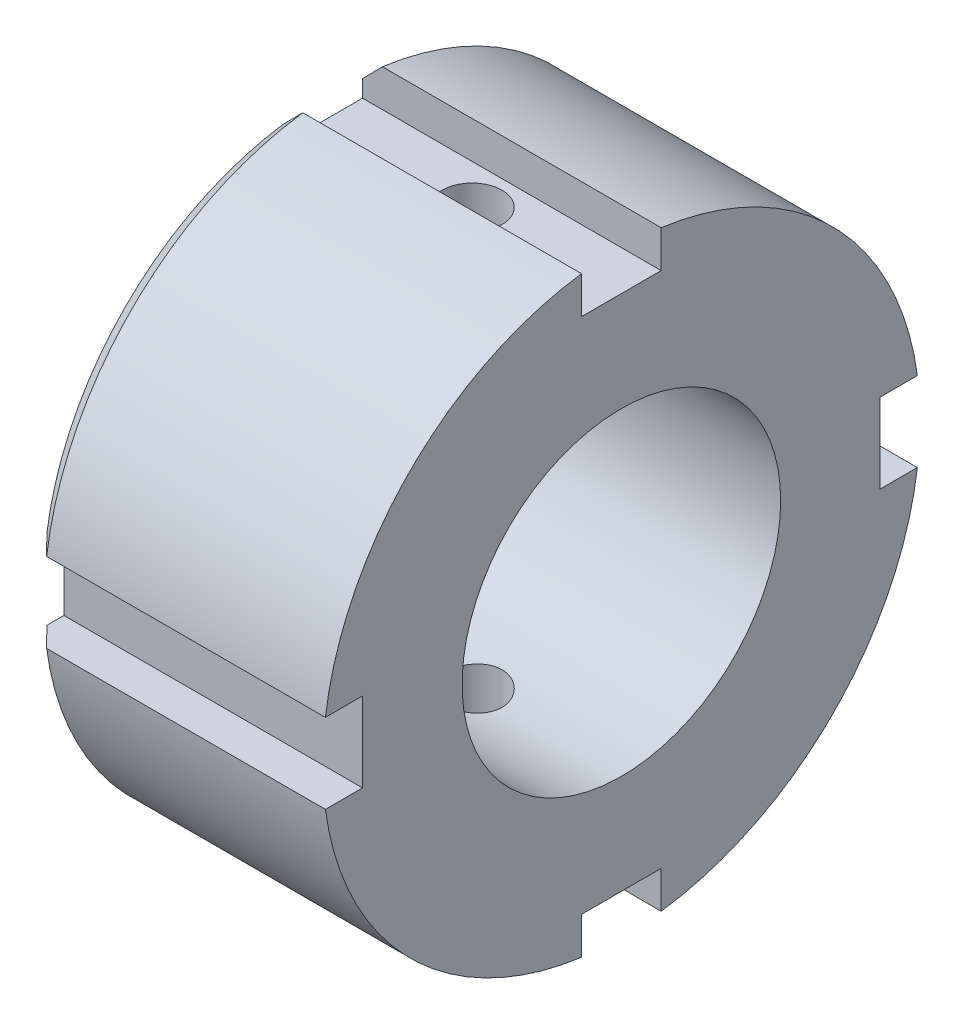
from build123d import *

# Parameters (mm, degrees)
SKETCH1_R               = 15
BOSS_EXTRUDE1_DEPTH     = 15
SKETCH2_R               = 8
CUT_EXTRUDE1_DEPTH      = 16
CHAMFER1_SIZE           = 1
SKETCH3_W               = 4
SKETCH3_H               = 4
CUT_EXTRUDE2_DEPTH      = 16
CIRPATTERN1_COUNT       = 4
SKETCH4_R               = 1.5
CUT_EXTRUDE4_DEPTH      = 18
CUT_EXTRUDE4_DEPTH_BACK = 15.866068747


with BuildPart() as part:
    # Sketch1 → Boss-Extrude1 (new body)
    with BuildSketch(Plane(origin=(0, 0, 0), x_dir=(0, 0, -1), z_dir=(1, 0, 0))):
        Circle(SKETCH1_R)
    extrude(amount=BOSS_EXTRUDE1_DEPTH)

    # Sketch2 → Cut-Extrude1 (cut, through all)
    with BuildSketch(Plane(origin=(15, 0, 0), x_dir=(0, 0, -1), z_dir=(1, 0, 0))):
        Circle(SKETCH2_R)
    extrude(amount=-CUT_EXTRUDE1_DEPTH, mode=Mode.SUBTRACT)

    # Chamfer1
    chamfer1_edges = [part.edges().sort_by_distance(p)[0] for p in [
        (0, 0, 15),
    ]]
    chamfer(chamfer1_edges, length=CHAMFER1_SIZE)

    # Sketch3 → Cut-Extrude2 (cut, through all)
    with BuildSketch(Plane(origin=(15, 0, 0), x_dir=(0, 0, -1), z_dir=(1, 0, 0))):
        with Locations((0, 15)):
            Rectangle(SKETCH3_W, SKETCH3_H)
    cut_extrude2 = extrude(amount=-CUT_EXTRUDE2_DEPTH, mode=Mode.SUBTRACT)

    # CirPattern1: Cut-Extrude2 ×4 about axis
    cirpattern1_axis = Axis((0, 0, 0), (1, 0, 0))
    for i in range(1, CIRPATTERN1_COUNT):
        add(cut_extrude2.rotate(cirpattern1_axis, i * 360 / CIRPATTERN1_COUNT), mode=Mode.SUBTRACT)

    # Sketch4 → Cut-Extrude4 (cut, two sides)
    with BuildSketch(Plane(origin=(0, 0, 0), x_dir=(1, 0, 0), z_dir=(0, 1, 0))) as cut_extrude4_sk:
        with Locations((7.5, 0)):
            Circle(SKETCH4_R)
    extrude(amount=CUT_EXTRUDE4_DEPTH, mode=Mode.SUBTRACT)
    extrude(cut_extrude4_sk.sketch, amount=-CUT_EXTRUDE4_DEPTH_BACK, mode=Mode.SUBTRACT)


solid = part.part
